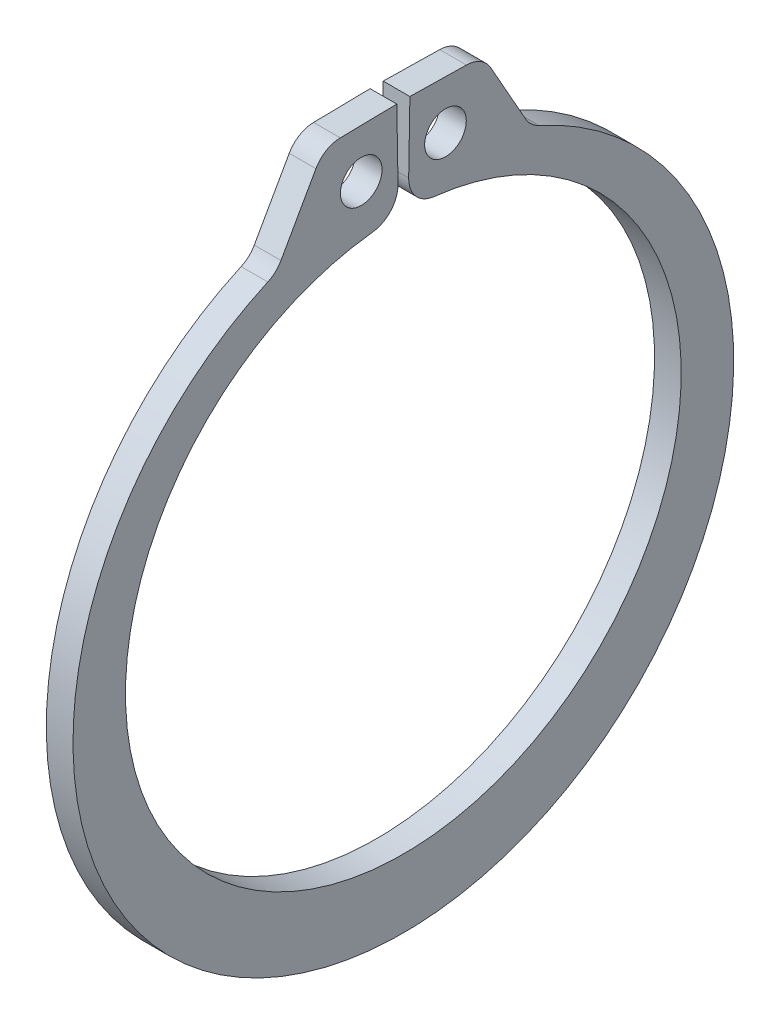
from build123d import *

# Parameters (mm, degrees)
SKETCH3_R                = 0.9906
BOSS_EXTRUDE1_DEPTH      = 0.635
BOSS_EXTRUDE1_DEPTH_BACK = 0.635
FILLET1_R                = 1.3589


with BuildPart() as part:
    # Sketch3 → Boss-Extrude1 (new body, two sides)
    with BuildSketch(Plane(origin=(0, 0, 0), x_dir=(0, 0, -1), z_dir=(1, 0, 0))) as boss_extrude1_sk:
        with BuildLine():
            Line((-3.777983958, 17.78027311), (-6.047809043, 13.75309371))
            ThreePointArc((-6.047809043, 13.75309371), (0, -16.4719), (6.047809043, 13.75309371))
            Line((6.047809043, 13.75309371), (3.777983958, 17.78027311))
            Line((3.777983958, 17.78027311), (0.311412014, 17.840782349))
            Line((0.311412014, 17.840782349), (0.23073303, 13.218686423))
            ThreePointArc((0.23073303, 13.218686423), (0, -13.2207), (-0.23073303, 13.218686423))
            Line((-0.23073303, 13.218686423), (-0.311412014, 17.840782349))
            Line((-0.311412014, 17.840782349), (-3.777983958, 17.78027311))
        make_face()
        with Locations((-2.004358494, 15.499479767)):
            Circle(SKETCH3_R, mode=Mode.SUBTRACT)
        with Locations((2.004358494, 15.499479767)):
            Circle(SKETCH3_R, mode=Mode.SUBTRACT)
    extrude(amount=BOSS_EXTRUDE1_DEPTH)
    extrude(boss_extrude1_sk.sketch, amount=-BOSS_EXTRUDE1_DEPTH_BACK)

    # Fillet1
    fillet1_edges = [part.edges().sort_by_distance(p)[0] for p in [
        (0, 13.75309371, 6.047809043),
        (0, 17.78027311, 3.777983958),
        (0, 13.218686423, 0.23073303),
        (0, 13.218686423, -0.23073303),
        (0, 17.78027311, -3.777983958),
        (0, 13.75309371, -6.047809043),
    ]]
    fillet(fillet1_edges, radius=FILLET1_R)


solid = part.part
